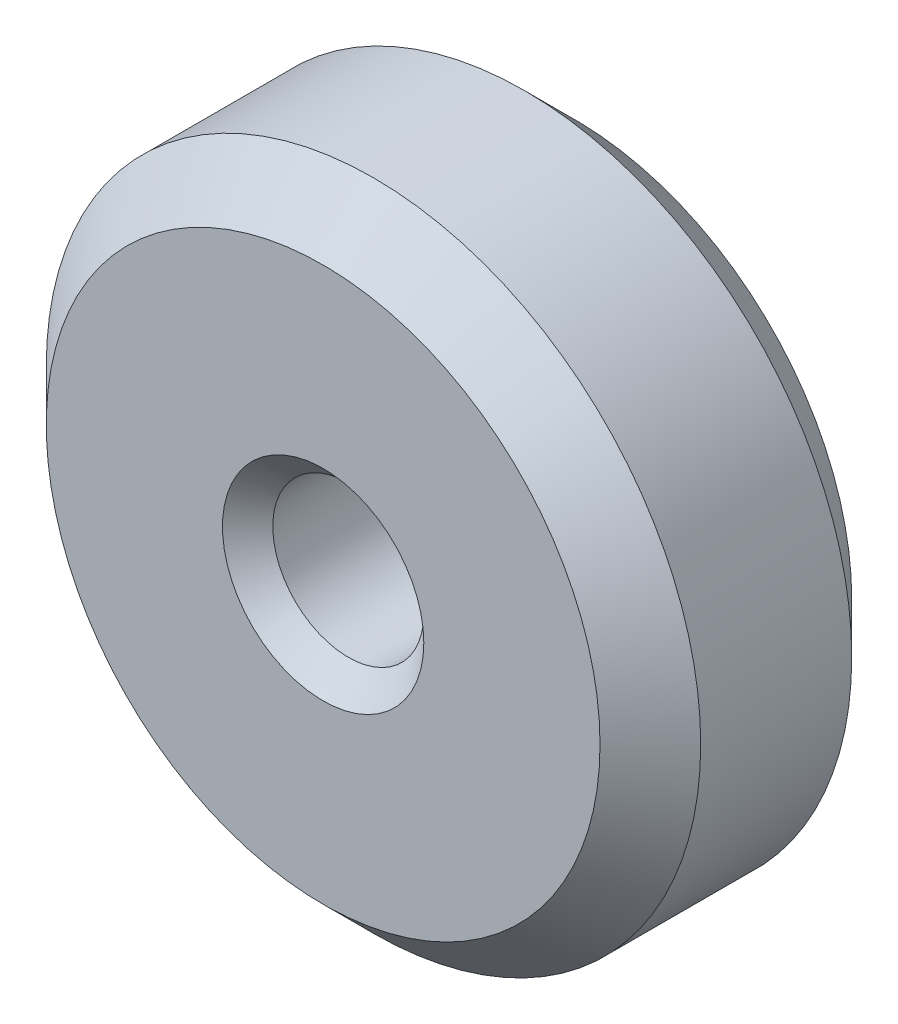
from build123d import *

# Parameters (mm, degrees)
SKETCH_1_R      = 6.5
SKETCH_1_R_2    = 1.5
EXTRUDE_1_DEPTH = 5
CHAMFER_1_SIZE  = 1
CHAMFER_2_SIZE  = 0.5


with BuildPart() as part:
    # 草图1 → 凸台-拉伸1 (new body)
    with BuildSketch(Plane.XY):
        Circle(SKETCH_1_R)
        Circle(SKETCH_1_R_2, mode=Mode.SUBTRACT)
    extrude(amount=EXTRUDE_1_DEPTH)

    # 倒角1
    chamfer_1_edges = [part.edges().sort_by_distance(p)[0] for p in [
        (-6.5, 0, 0),
        (-6.5, 0, 5),
    ]]
    chamfer(chamfer_1_edges, length=CHAMFER_1_SIZE)

    # 倒角2
    chamfer_2_edges = [part.edges().sort_by_distance(p)[0] for p in [
        (-1.5, 0, 0),
        (-1.5, 0, 5),
    ]]
    chamfer(chamfer_2_edges, length=CHAMFER_2_SIZE)


solid = part.part
